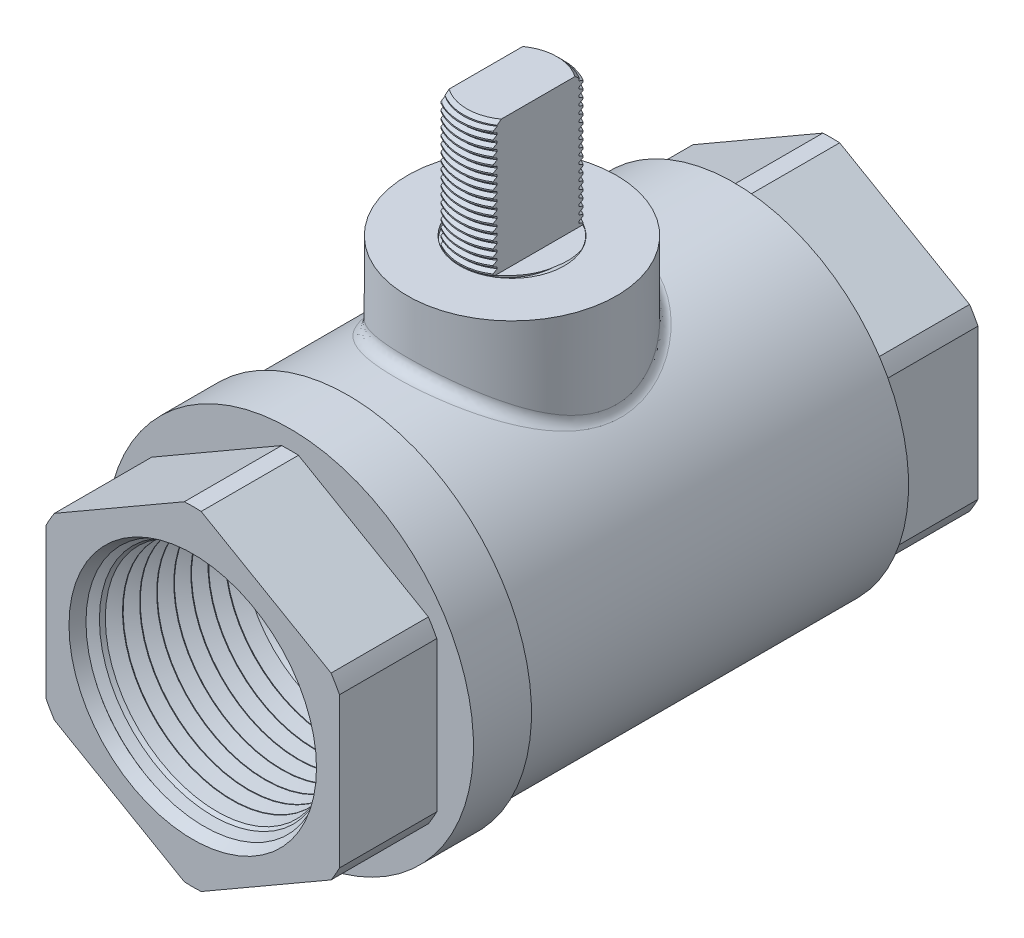
from build123d import *

# Parameters (mm, degrees)
EXTRUDE1_DEPTH       = 69.85
CHAMFER1_SIZE        = 0.762
FILLET5_R            = 1.27
LPATTERN1_COUNT      = 2
LPATTERN1_PITCH      = 0.79375
LPATTERN1_COL_COUNT  = 19
LPATTERN1_COL_PITCH  = 0.79375
SKETCH26_R           = 5.7277
EXTRUDE8_DEPTH       = 0.127
SKETCH16_W           = 10.6426
SKETCH16_H           = 0.508
SKETCH27_OUTSIDE_W   = 62.312
SKETCH27_OUTSIDE_H   = 92.03
SKETCH27_OUTSIDE_W_2 = 5.7023
SKETCH27_OUTSIDE_H_2 = 11.4046
CUT_EXTRUDE3_DEPTH   = 14.478


with BuildPart() as part:
    # Sketch1 → Revolve1 (revolve)
    with BuildSketch(Plane(origin=(0, -2.929502347, 125.566843264), x_dir=(0, 0, -1), z_dir=(1, 0, 0))):
        Polygon((143.499243264, 2.929502347), (143.499243264, 14.424410045), (143.531938974, 14.48536174), (144.32416871, 15.962244955), (144.393302281, 15.964405487), (145.276205796, 14.539872802), (145.345339366, 14.542033334), (146.137569103, 16.018916549), (146.206702674, 16.021077081), (147.089606188, 14.596544396), (147.158739759, 14.598704928), (147.950969495, 16.075588143), (148.020103066, 16.077748675), (148.903006581, 14.65321599), (148.972140151, 14.655376522), (149.764369888, 16.132259737), (149.833503459, 16.134420269), (150.716406973, 14.709887585), (150.785540544, 14.712048117), (151.57777028, 16.188931332), (151.646903851, 16.191091864), (152.529807366, 14.766559179), (152.598940936, 14.768719711), (153.391170673, 16.245602926), (153.460304244, 16.247763458), (154.343207758, 14.823230773), (154.412341329, 14.825391305), (155.204571065, 16.30227452), (155.273704636, 16.304435052), (156.156608151, 14.879902367), (156.225741721, 14.882062899), (157.017971458, 16.358946114), (157.087105029, 16.361106647), (157.970008543, 14.936573962), (158.039142114, 14.938734494), (158.83137185, 16.415617709), (158.900505421, 16.417778241), (159.783408935, 14.993245556), (159.852542506, 14.995406088), (160.644772243, 16.472289303), (160.713905814, 16.474449835), (161.596809328, 15.04991715), (161.665942899, 15.052077682), (162.458172635, 16.528960897), (162.527306206, 16.531121429), (163.41020972, 15.106588744), (163.479343291, 15.108749276), (164.271573028, 16.585632492), (164.340706598, 16.587793024), (165.223610113, 15.163260339), (165.292743684, 15.165420871), (166.08497342, 16.642304086), (166.154106991, 16.644464618), (167.037010505, 15.219931933), (167.106144076, 15.222092465), (167.898373813, 16.69897568), (167.967507383, 16.701136212), (168.850410898, 15.276603527), (168.919544469, 15.278764059), (169.711774205, 16.755647274), (169.780907776, 16.757807806), (170.66381129, 15.333275121), (170.732944861, 15.335435654), (170.732944861, 2.929502347), align=None)
    revolve(axis=Axis((0, 0, -17.9324), (0, 0, 1)))

    # Sketch6 → Cut-Revolve3 (revolve, cut)
    with BuildSketch(Plane(origin=(0, 0, 0), x_dir=(0, 0, -1), z_dir=(1, 0, 0))):
        Polygon((34.925, 0), (34.925, 13.538007687), (45.166101597, 13.858058105), (45.166101597, 0), align=None)
    revolve(axis=Axis((0, 0, -45.166101597), (0, 0, 1)), mode=Mode.SUBTRACT)

    # Sketch7 → Revolve3 (revolve)
    with BuildSketch(Plane(origin=(0, 0, 0), x_dir=(0, 0, -1), z_dir=(1, 0, 0)), mode=Mode.PRIVATE) as revolve3_sk:
        Polygon((31.8008, 11.988246759), (34.925, 13.538007687), (34.925, 12.085882888), align=None)
        Polygon((0, 0), (17.9324, 0), (17.9324, 11.494907698), (16.597492302, 10.16), (0, 10.16), align=None)
    revolve(revolve3_sk.sketch.rotate(Axis((0, 0, -17.9324), (0, 0, -1)), 270), axis=Axis((0, 0, -17.9324), (0, 0, -1)))

    # Mirror2: part across plane


with BuildPart() as part_1:
    add(part.part)
    add(part.part.mirror(Plane.XY))


with BuildPart() as body_2:
    # Sketch8 → Extrude1 (new body)
    with BuildSketch(Plane.XY.offset(34.925)):
        Polygon((0, 18.536176802), (-16.0528, 9.268088401), (-16.0528, -9.268088401), (0, -18.536176802), (16.0528, -9.268088401), (16.0528, 9.268088401), align=None)
    extrude(amount=-EXTRUDE1_DEPTH)

    # Sketch9 → Revolve4 (revolve)
    with BuildSketch(Plane(origin=(0, 0, 0), x_dir=(0, 0, -1), z_dir=(1, 0, 0)), mode=Mode.PRIVATE) as revolve4_sk:
        Polygon((-24.2824, 9.268088401), (-24.2824, 20.066), (-17.9324, 20.066), (-17.9324, 19.500886275), (-17.532804253, 19.101290528), (24.2824, 19.101290528), (24.2824, 9.268088401), align=None)
    revolve(revolve4_sk.sketch.rotate(Axis((0, 0, 0), (0, 0, 1)), 90), axis=Axis((0, 0, 0), (0, 0, 1)))

    # Sketch10 → Revolve5 (revolve)
    with BuildSketch(Plane(origin=(0, 0, 0), x_dir=(0, 0, -1), z_dir=(1, 0, 0))):
        Polygon((0, 1.27), (0, 25.425890528), (5.7277, 25.425890528), (5.7277, 26.213290528), (11.43, 26.213290528), (11.43, 1.27), align=None)
        Polygon((5.7023, 26.213290528), (5.7023, 40.691290528), (0, 40.691290528), (0, 25.451290528), (5.7023, 25.451290528), align=None)
    revolve(axis=Axis((0, 0, 0), (0, 1, 0)))


with BuildPart() as revolve5_piece_1:
    # of the separate pieces the step leaves, piece 1, a body of its own (revolve5_pieces)
    add(body_2.part.solids().sort_by_distance((0, 18.536176802, 34.925))[0])

    # Fillet5
    fillet5_edges = [revolve5_piece_1.edges().sort_by_distance(p)[0] for p in [
        (0, 19.101290528, 11.43),
    ]]
    fillet(fillet5_edges, radius=FILLET5_R)



with BuildPart() as revolve5_piece_2:
    # of the separate pieces the step leaves, piece 2, a body of its own (revolve5_pieces)
    add(body_2.part.solids().sort_by_distance((0, 40.691290528, -5.7023))[0])

    # Chamfer1
    chamfer1_edges = [revolve5_piece_2.edges().sort_by_distance(p)[0] for p in [
        (0, 40.691290528, 5.7023),
    ]]
    chamfer(chamfer1_edges, length=CHAMFER1_SIZE)

    # Sketch20 → Cut-Revolve6 (revolve, cut)
    with BuildSketch(Plane(origin=(0, 0, 0), x_dir=(0, 0, -1), z_dir=(1, 0, 0)), mode=Mode.PRIVATE) as cut_revolve6_sk:
        Polygon((5.709188872, 40.592311218), (5.757410974, 39.899456048), (5.311595811, 40.117074633), (5.297818067, 40.315033253), align=None)
    cut_revolve6 = revolve(cut_revolve6_sk.sketch.rotate(Axis((0, 40.691290528, 0.058772234), (0, -0.9975867458907851, -0.06943114879529466)), 180), axis=Axis((0, 40.691290528, 0.058772234), (0, -0.9975867458907851, -0.06943114879529466)), mode=Mode.SUBTRACT)

    # LPattern1: Cut-Revolve6 ×2
    with Locations(*[(0, i * LPATTERN1_PITCH, 0) for i in range(1, LPATTERN1_COUNT)]):
        add(cut_revolve6, mode=Mode.SUBTRACT)

    # LPattern1 col: Cut-Revolve6 ×19
    with Locations(*[(0, -i * LPATTERN1_COL_PITCH, 0) for i in range(1, LPATTERN1_COL_COUNT)]):
        add(cut_revolve6, mode=Mode.SUBTRACT)


with BuildPart() as revolve5_piece_1_1:
    add(revolve5_piece_1.part)

    add(revolve5_piece_2.part)  # Extrude8 merges Revolve5 piece 2
    # Sketch26 → Extrude8 (add)
    with BuildSketch(Plane(origin=(0, 25.425890528, 0), x_dir=(-1, 0, 0), z_dir=(0, 1, 0))):
        with Locations(Location((0, 0, 0), (0, 0, 270))):
            Circle(SKETCH26_R)
    extrude(amount=EXTRUDE8_DEPTH)

    # Sketch16 → Cut-Revolve5 (revolve, cut)
    with BuildSketch(Plane(origin=(0, 0, 0), x_dir=(0, 0, -1), z_dir=(1, 0, 0)), mode=Mode.PRIVATE) as cut_revolve5_sk:
        with Locations((29.6037, 18.282176802)):
            Rectangle(SKETCH16_W, SKETCH16_H)
        with Locations((-29.6037, 18.282176802)):
            Rectangle(SKETCH16_W, SKETCH16_H)
    revolve(cut_revolve5_sk.sketch.rotate(Axis((0, 0, 0), (0, 0, 1)), 90), axis=Axis((0, 0, 0), (0, 0, 1)), mode=Mode.SUBTRACT)

    # Combine1: cut part
    add(part_1.part, mode=Mode.SUBTRACT)

    # Sketch27 outside → Cut-Extrude3 (cut)
    with BuildSketch(Plane(origin=(0, 40.691290528, 0), x_dir=(-1, 0, 0), z_dir=(0, 1, 0))):
        Rectangle(SKETCH27_OUTSIDE_W, SKETCH27_OUTSIDE_H)
        Rectangle(SKETCH27_OUTSIDE_W_2, SKETCH27_OUTSIDE_H_2, mode=Mode.SUBTRACT)
    extrude(amount=-CUT_EXTRUDE3_DEPTH, mode=Mode.SUBTRACT)


solid = revolve5_piece_1_1.part
